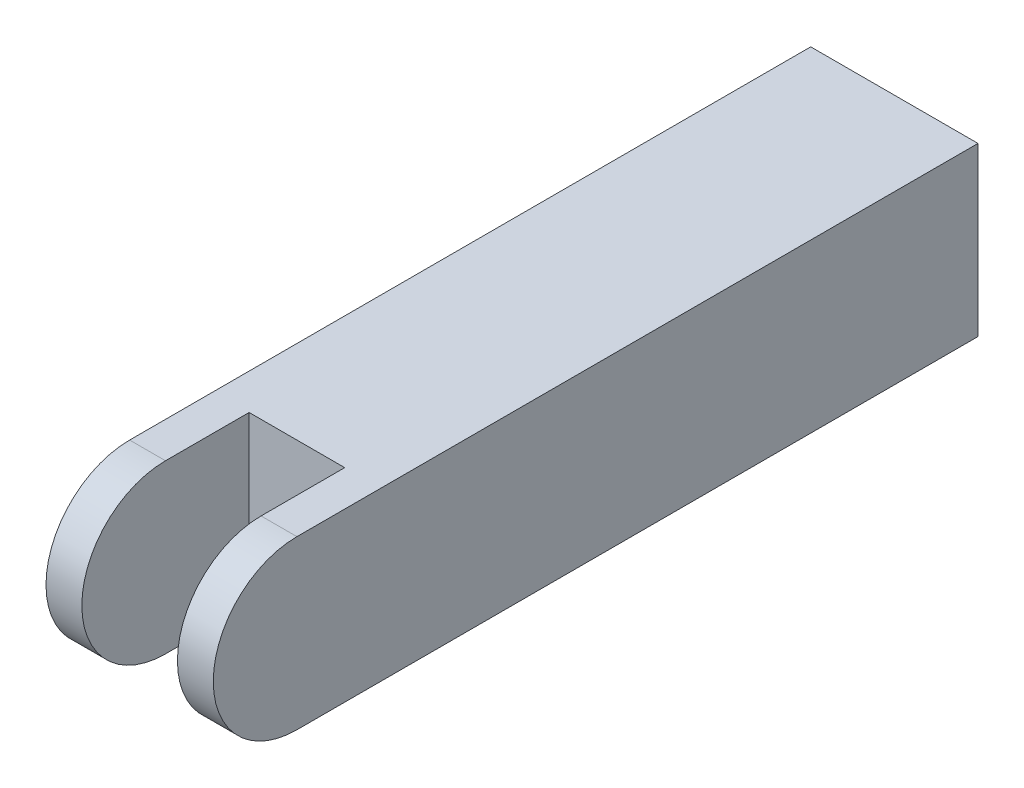
from build123d import *

# Parameters (mm, degrees)
SKETCH_1_W          = 14
SKETCH_1_H          = 14
EXTRUDE_1_DEPTH     = 64
CUT_EXTRUDE_1_DEPTH = 64
SKETCH_3_W          = 8
SKETCH_3_H          = 14
CUT_EXTRUDE_2_DEPTH = 15


with BuildPart() as part:
    # 草图1 → 凸台-拉伸1 (new body)
    with BuildSketch(Plane.XY):
        Rectangle(SKETCH_1_W, SKETCH_1_H)
    extrude(amount=EXTRUDE_1_DEPTH)

    # 草图2 → 切除-拉伸1 (cut)
    with BuildSketch(Plane(origin=(7, 0, 0), x_dir=(0, 0, -1), z_dir=(1, 0, 0))):
        with BuildLine():
            Line((-57, 7), (-68.546767236, 7))
            Line((-68.546767236, 7), (-68.546767236, -7))
            Line((-68.546767236, -7), (-57, -7))
            ThreePointArc((-57, -7), (-64, 0), (-57, 7))
        make_face()
    extrude(amount=-CUT_EXTRUDE_1_DEPTH, mode=Mode.SUBTRACT)

    # 草图3 → 切除-拉伸2 (cut, through all)
    with BuildSketch(Plane(origin=(0, 7, 0), x_dir=(1, 0, 0), z_dir=(0, 1, 0))):
        with Locations((0, -57)):
            Rectangle(SKETCH_3_W, SKETCH_3_H)
    extrude(amount=-CUT_EXTRUDE_2_DEPTH, mode=Mode.SUBTRACT)


solid = part.part
